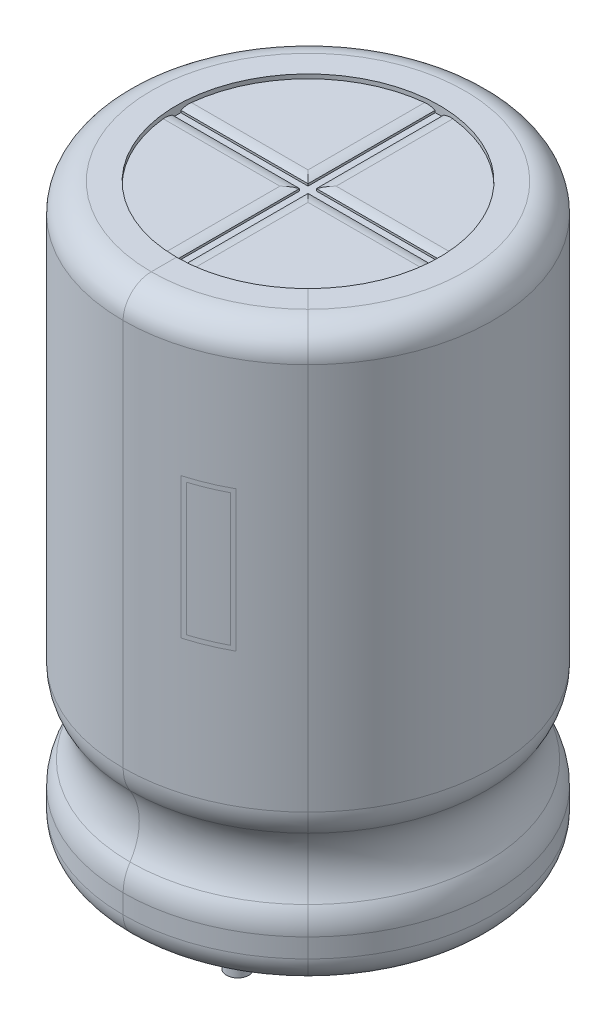
from build123d import *

# Parameters (mm, degrees)
SKETCH1_W           = 4.675
SKETCH1_H           = 1
CUT_EXTRUDE1_DEPTH  = 22.064454657
CIRPATTERN1_COUNT   = 2
CIRPATTERN1_ANGLE   = 90
SKETCH5_R           = 0.4
BOSS_EXTRUDE1_DEPTH = 2.85


with BuildPart() as part:
    # Sketch1 → Revolve1 (revolve)
    with BuildSketch(Plane(origin=(0, 0, 0), x_dir=(0, 0, -1), z_dir=(1, 0, 0))):
        with Locations((2.3375, 19.5)):
            Rectangle(SKETCH1_W, SKETCH1_H)
    revolve(axis=Axis((0, 33.37320456, 0), (0, -1, 0)))

    # Sketch2 → Cut-Extrude1 (cut, symmetric)
    with BuildSketch(Plane(origin=(0, 0, 0), x_dir=(0, 0, -1), z_dir=(1, 0, 0))):
        with BuildLine():
            Line((-0.5, 20), (0.5, 20))
            ThreePointArc((0.5, 20), (0.321027237, 19.981039562), (0.15, 19.925))
            Line((0.15, 19.925), (0.15, 19.85))
            Line((0.15, 19.85), (-0.15, 19.85))
            Line((-0.15, 19.85), (-0.15, 19.925))
            ThreePointArc((-0.15, 19.925), (-0.321027237, 19.981039562), (-0.5, 20))
        make_face()
    cut_extrude1 = extrude(amount=CUT_EXTRUDE1_DEPTH, both=True, mode=Mode.SUBTRACT)

    # CirPattern1: Cut-Extrude1 ×2 about axis
    cirpattern1_axis = Axis((0, 33.37320456, 0), (0, 1, 0))
    for i in range(1, CIRPATTERN1_COUNT):
        add(cut_extrude1.rotate(cirpattern1_axis, i * CIRPATTERN1_ANGLE / (CIRPATTERN1_COUNT - 1)), mode=Mode.SUBTRACT)

    # Sketch1_3 → Revolve2 (revolve)
    with BuildSketch(Plane(origin=(0, 0, 0), x_dir=(0, 0, -1), z_dir=(1, 0, 0))):
        with BuildLine():
            Line((4.675, 20.15), (4.675, 20))
            Line((4.675, 20), (4.675, 19))
            Line((4.675, 19), (0, 19))
            Line((0, 19), (0, 0))
            Line((0, 0), (5.425, 0))
            Line((5.425, 0), (5.425, -0.15))
            Line((5.425, -0.15), (5.575, -0.15))
            ThreePointArc((5.575, -0.15), (6.282106781, 0.142893219), (6.575, 0.85))
            Line((6.575, 0.85), (6.575, 1.527924299))
            ThreePointArc((6.575, 1.527924299), (6.512072918, 1.957832927), (6.328571429, 2.351671028))
            ThreePointArc((6.328571429, 2.351671028), (6, 3.45), (6.328571429, 4.548328972))
            ThreePointArc((6.328571429, 4.548328972), (6.512072918, 4.942167073), (6.575, 5.372075701))
            Line((6.575, 5.372075701), (6.575, 19.15))
            ThreePointArc((6.575, 19.15), (6.282106781, 19.857106781), (5.575, 20.15))
            Line((5.575, 20.15), (4.675, 20.15))
        make_face()
    revolve(axis=Axis((0, 33.37320456, 0), (0, -1, 0)))

    # Sketch5 → Boss-Extrude1 (add)
    with BuildSketch(Plane.XZ):
        with Locations((0, 2.5)):
            Circle(SKETCH5_R)
        with Locations((0, -2.5)):
            Circle(SKETCH5_R)
    extrude(amount=BOSS_EXTRUDE1_DEPTH)


solid = part.part
